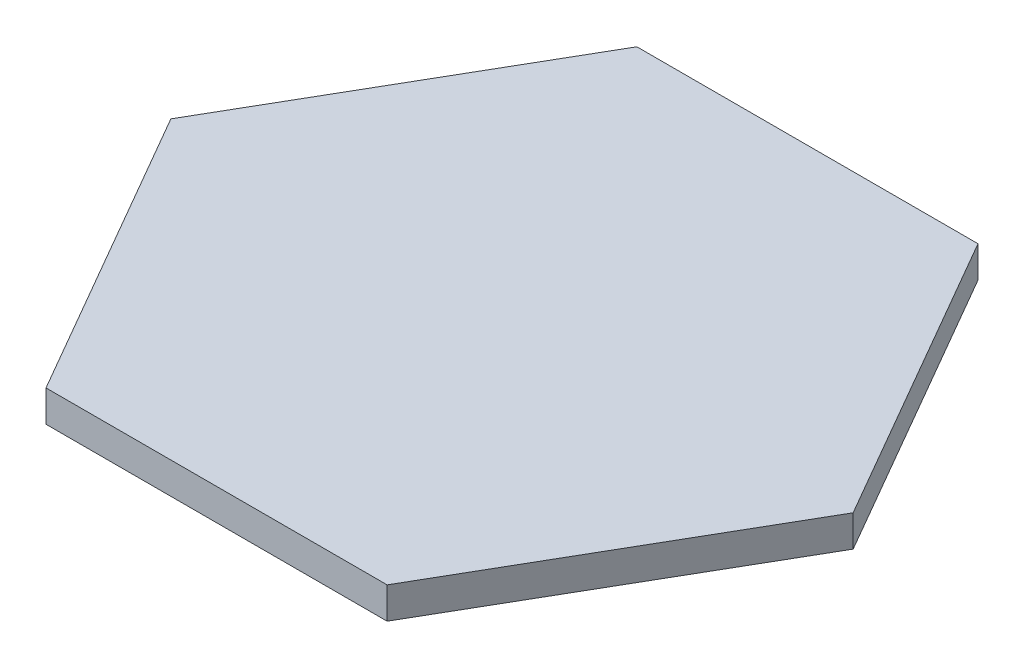
from build123d import *

# Parameters (mm, degrees)
SALIENTE_EXTRUIR1_DEPTH = 3


with BuildPart() as part:
    # Croquis1 → Saliente-Extruir1 (new body)
    with BuildSketch(Plane(origin=(0, 0, 0), x_dir=(1, 0, 0), z_dir=(0, 1, 0))):
        Polygon((-32.5, 0), (-16.25, -28.145825623), (16.25, -28.145825623), (32.5, 0), (16.25, 28.145825623), (-16.25, 28.145825623), align=None)
    extrude(amount=SALIENTE_EXTRUIR1_DEPTH)


solid = part.part
